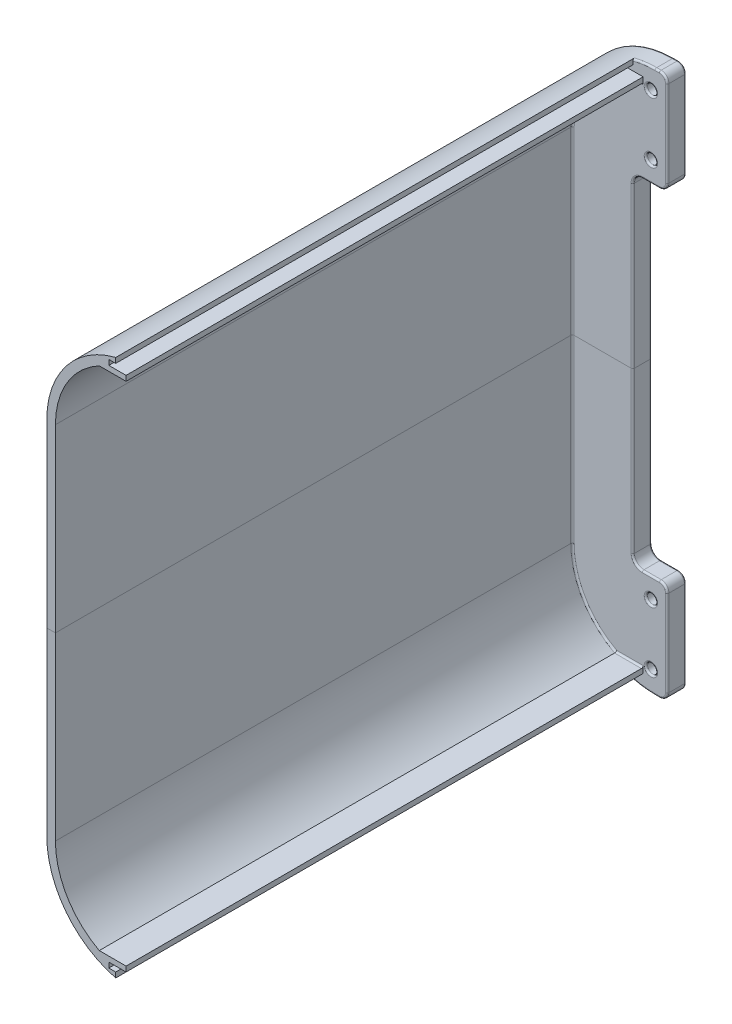
from build123d import *

# Parameters (mm, degrees)
SKETCH2_R           = 1.600000000000004
BOSS_EXTRUDE1_DEPTH = 11
SKETCH3_R           = 2.875000000000001
CUT_EXTRUDE1_DEPTH  = 9
BOSS_EXTRUDE2_DEPTH = 300
FILLET1_R           = 1


with BuildPart() as part:
    # Sketch2 → Boss-Extrude1 (new body)
    with BuildSketch(Plane.XY):
        with BuildLine():
            Line((-10.500000000001744, 116.9948864065977), (-10.500000000001254, 210))
            Line((-10.500000000001254, 210), (-50.500000000001755, 210))
            Line((-50.500000000001755, 210), (-50.50000000000173, 105.39999999999998))
            ThreePointArc((-50.50000000000173, 105.39999999999998), (-35.004450987938846, 67.99043541866078), (2.4051135934003534, 52.494886406597914))
            Line((2.4051135934003534, 52.494886406597914), (5.00000000000717, 52.49488640659788))
            ThreePointArc((5.00000000000717, 52.49488640659788), (8.181980515346671, 53.81290589125848), (9.50000000000693, 56.99488640659804))
            Line((9.50000000000693, 56.99488640659804), (9.500000000005219, 106.99488640659803))
            ThreePointArc((9.500000000005219, 106.99488640659803), (8.181980515345092, 110.17686692193625), (5.000000000006808, 111.49488640659668))
            Line((5.000000000006808, 111.49488640659668), (-5.000000000001575, 111.4948864065978))
            ThreePointArc((-5.000000000001575, 111.4948864065978), (-8.889087296527661, 113.10579911007164), (-10.500000000001744, 116.9948864065977))
        make_face()
        with Locations(Location((-3.1572e-13, 99.49488640659804, 0), (0, 0, 270))):
            Circle(SKETCH2_R, mode=Mode.SUBTRACT)
        with Locations(Location((-3.1143e-13, 64.49488640659803, 0), (0, 0, 180))):
            Circle(SKETCH2_R, mode=Mode.SUBTRACT)
    extrude(amount=BOSS_EXTRUDE1_DEPTH)

    # Sketch3 → Cut-Extrude1 (cut)
    with BuildSketch(Plane.XY.offset(11.000000000000385)):
        with Locations((-3.1546e-13, 99.49488640659804)):
            Circle(SKETCH3_R)
        with Locations((-3.1117e-13, 64.49488640659803)):
            Circle(SKETCH3_R)
    extrude(amount=-CUT_EXTRUDE1_DEPTH, mode=Mode.SUBTRACT)

    # Sketch4 → Boss-Extrude2 (add)
    with BuildSketch(Plane.XY.offset(11.000000000000385)):
        with BuildLine():
            Line((-10.500000000000435, 54.09299182887195), (-10.500000000000435, 57.09299182887195))
            Line((-10.500000000000435, 57.09299182887195), (-14.500000000000437, 57.09299182887195))
            Line((-14.500000000000437, 57.09299182887195), (-14.500000000000437, 60.09299182887195))
            Line((-14.500000000000437, 60.09299182887195), (-4.500000000000436, 60.09299182887195))
            Line((-4.500000000000436, 60.09299182887195), (-4.500000000000436, 63.092991828871945))
            Line((-4.500000000000436, 63.092991828871945), (-20.067468990825734, 63.092991828871945))
            ThreePointArc((-20.067468990825734, 63.092991828871945), (-38.65247723844962, 80.71854656870569), (-45.500000000001755, 105.39999999999998))
            Line((-45.500000000001755, 105.39999999999998), (-45.500000000001755, 210))
            Line((-45.500000000001755, 210), (-50.500000000001755, 210))
            Line((-50.500000000001755, 210), (-50.50000000000173, 105.39999999999998))
            ThreePointArc((-50.50000000000173, 105.39999999999998), (-39.31836627660453, 72.87151599185606), (-10.500000000000435, 54.09299182887195))
        make_face()
    extrude(amount=BOSS_EXTRUDE2_DEPTH)

    # Fillet1
    fillet1_edges = [part.edges().sort_by_distance(p)[0] for p in [
        (-50.50000000000174, 157.7, 0),
        (-35.00445098793885, 67.99043541866078, 0),
        (3.702556796703762, 52.4948864065979, 0),
        (8.181980515346643, 53.81290589125845, 0),
        (-10.5000000000015, 163.49744320329884, 0),
        (-8.889087296527688, 113.10579911007167, 0),
        (2.61657e-12, 111.49488640659723, 0),
        (8.181980515345028, 110.17686692193632, 0),
        (-4.096730333503756, 52.89593282534239, 11),
        (3.702556796703762, 52.4948864065979, 11),
        (8.181980515346643, 53.81290589125845, 11),
        (-10.5000000000015, 163.49744320329884, 11),
        (-8.889087296527688, 113.10579911007167, 11),
        (2.61657e-12, 111.49488640659723, 11),
        (8.181980515345028, 110.17686692193632, 11),
        (9.500000000006075, 81.99488640659803, 0),
        (-2.8750000000003126, 64.49488640659803, 11.000000000000385),
        (-2.8750000000003166, 99.49488640659804, 11.000000000000385),
        (9.500000000006075, 81.99488640659803, 11),
        (-45.500000000001755, 157.7, 11.000000000000385),
        (-38.65247723844963, 80.71854656870568, 11.000000000000385),
        (-12.283734495413086, 63.092991828871945, 11.000000000000385),
    ]]
    fillet(fillet1_edges, radius=FILLET1_R)


with BuildPart() as body_2:
    # Mirror1: mirrored copy
    add(part.part.mirror(Plane(origin=(-50.500000000001755, 210, 179.5463165069818), x_dir=(0, 0, 1), z_dir=(0, -1, 0))))


solid = Compound([part.part, body_2.part])
